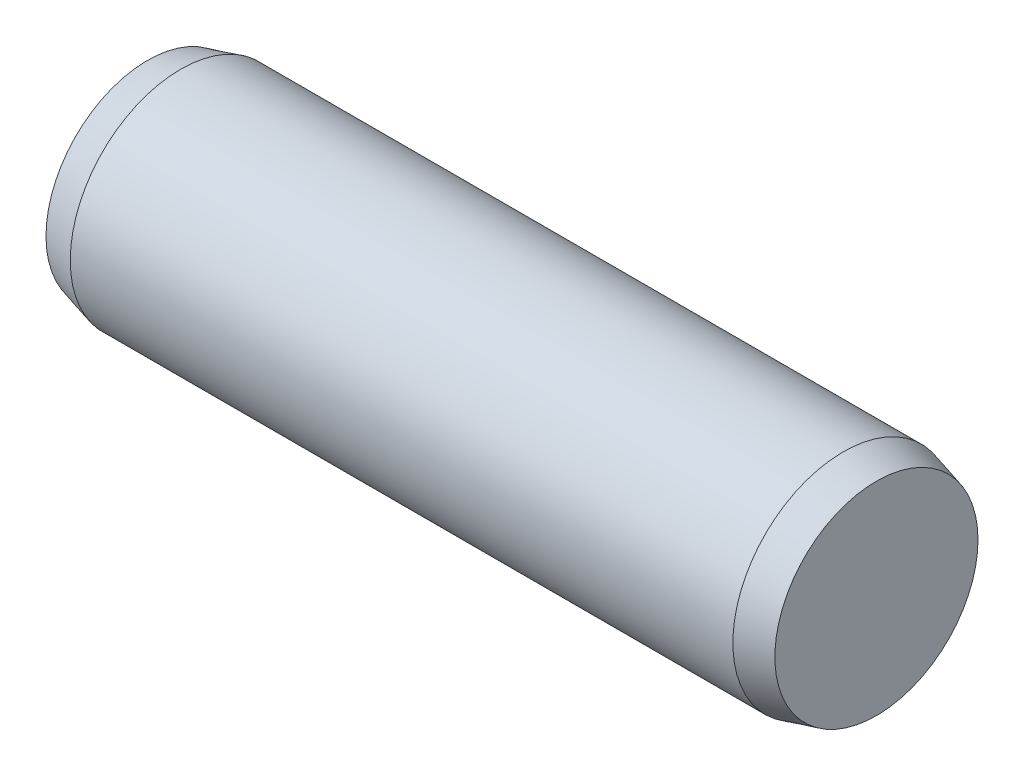
from build123d import *

# Parameters (mm, degrees)
SKETCH2_R           = 2
EXTRUDE1_DEPTH      = 6
EXTRUDE1_DEPTH_BACK = 6
SKETCH3_R           = 2
EXTRUDE2_DEPTH      = 0.6
EXTRUDE2_TAPER      = 15
SKETCH4_R           = 2
EXTRUDE3_DEPTH      = 0.6
EXTRUDE3_TAPER      = 15


with BuildPart() as part:
    # Sketch2 → Extrude1 (new body, two sides)
    with BuildSketch(Plane(origin=(0, 0, 0), x_dir=(0, 0, -1), z_dir=(1, 0, 0))) as extrude1_sk:
        Circle(SKETCH2_R)
    extrude(amount=EXTRUDE1_DEPTH)
    extrude(extrude1_sk.sketch, amount=-EXTRUDE1_DEPTH_BACK)

    # Sketch3 → Extrude2 (add)
    with BuildSketch(Plane(origin=(6, 0, 0), x_dir=(0, 0, -1), z_dir=(1, 0, 0))):
        Circle(SKETCH3_R)
    extrude(amount=EXTRUDE2_DEPTH, taper=EXTRUDE2_TAPER)

    # Sketch4 → Extrude3 (add)
    with BuildSketch(Plane.ZY.offset(6)):
        Circle(SKETCH4_R)
    extrude(amount=EXTRUDE3_DEPTH, taper=EXTRUDE3_TAPER)


solid = part.part
